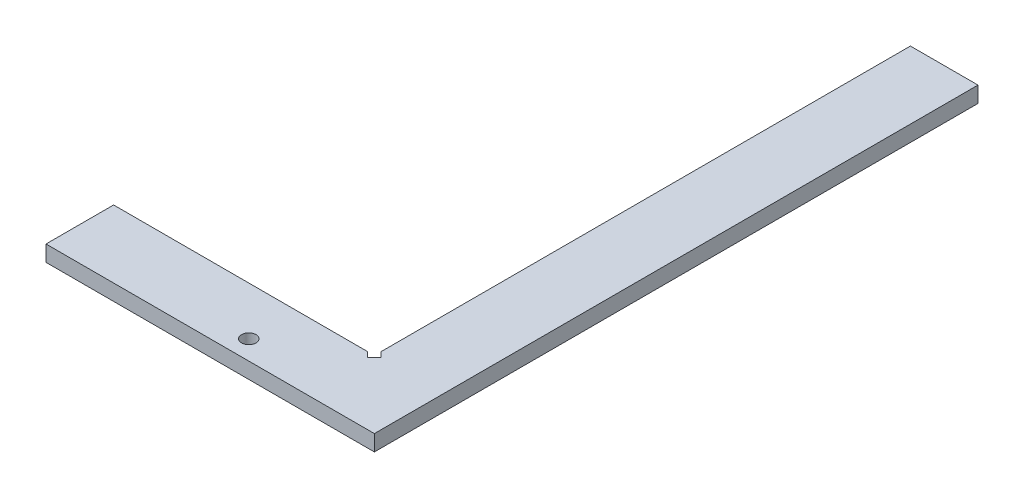
from build123d import *

# Parameters (mm, degrees)
SKETCH_1_R          = 1.5
EXTRUDE_1_DEPTH     = 3.3
CUT_EXTRUDE_1_DEPTH = 3.3


with BuildPart() as part:
    # Эскиз1 → Бобышка-Вытянуть1 (new body)
    with BuildSketch(Plane(origin=(0, 0, 0), x_dir=(1, 0, 0), z_dir=(0, 1, 0))):
        Polygon((0, 0), (0, 125), (-14, 125), (-14, 14), (-68, 14), (-68, 0), align=None)
        with Locations((-30, 4)):
            Circle(SKETCH_1_R, mode=Mode.SUBTRACT)
    extrude(amount=EXTRUDE_1_DEPTH)

    # Эскиз2 → Вырез-Вытянуть1 (cut)
    with BuildSketch(Plane(origin=(0, 3.3, 0), x_dir=(1, 0, 0), z_dir=(0, 1, 0))):
        Polygon((-15.4, 14), (-14.339339828, 12.939339828), (-12.939339828, 14.339339828), (-14, 15.4), align=None)
    extrude(amount=-CUT_EXTRUDE_1_DEPTH, mode=Mode.SUBTRACT)


solid = part.part
